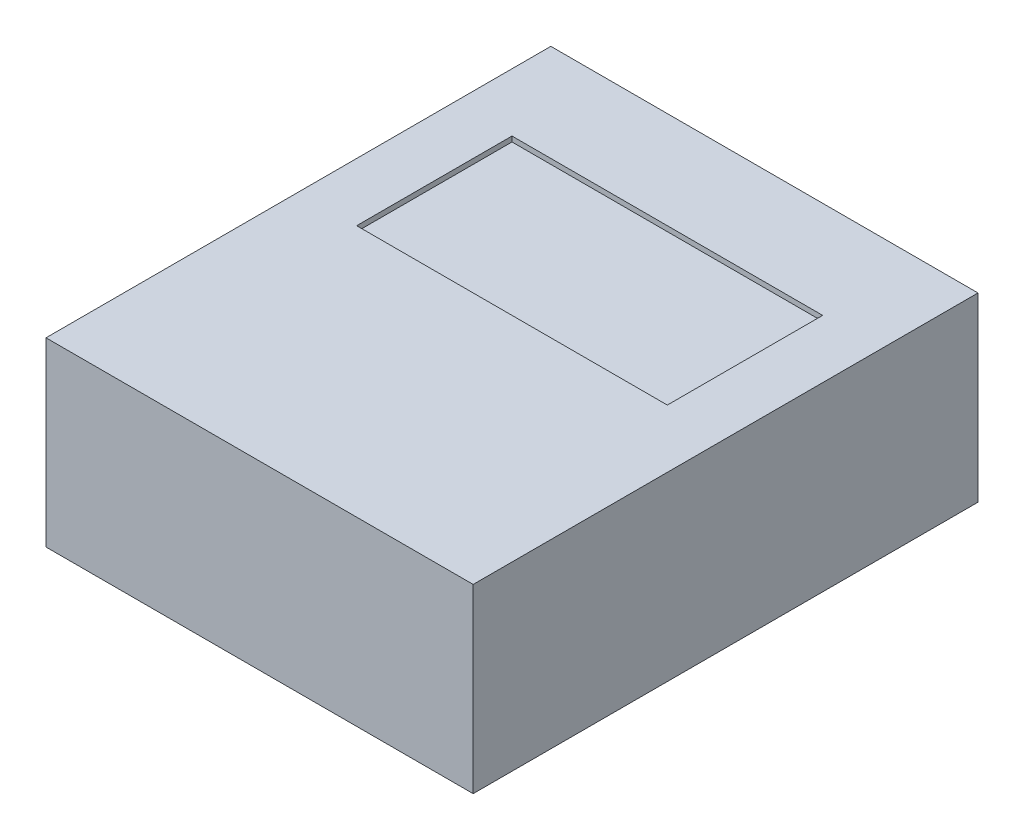
from build123d import *

# Parameters (mm, degrees)
ESQUISSE1_W             = 165
ESQUISSE1_H             = 195
BOSS_EXTRU_1_DEPTH      = 35
ESQUISSE4_W             = 120
ESQUISSE4_H             = 60
ENL_V_MAT_EXTRU_1_DEPTH = 2


with BuildPart() as part:
    # Esquisse1 → Boss.-Extru.1 (new body, symmetric)
    with BuildSketch(Plane(origin=(0, 0, 0), x_dir=(1, 0, 0), z_dir=(0, 1, 0))):
        Rectangle(ESQUISSE1_W, ESQUISSE1_H)
    extrude(amount=BOSS_EXTRU_1_DEPTH, both=True)

    # Esquisse4 → Enlèv. mat.-Extru.1 (cut)
    with BuildSketch(Plane(origin=(0, 35, 0), x_dir=(1, 0, 0), z_dir=(0, 1, 0))):
        with Locations((0, 30)):
            Rectangle(ESQUISSE4_W, ESQUISSE4_H)
    extrude(amount=-ENL_V_MAT_EXTRU_1_DEPTH, mode=Mode.SUBTRACT)


solid = part.part
